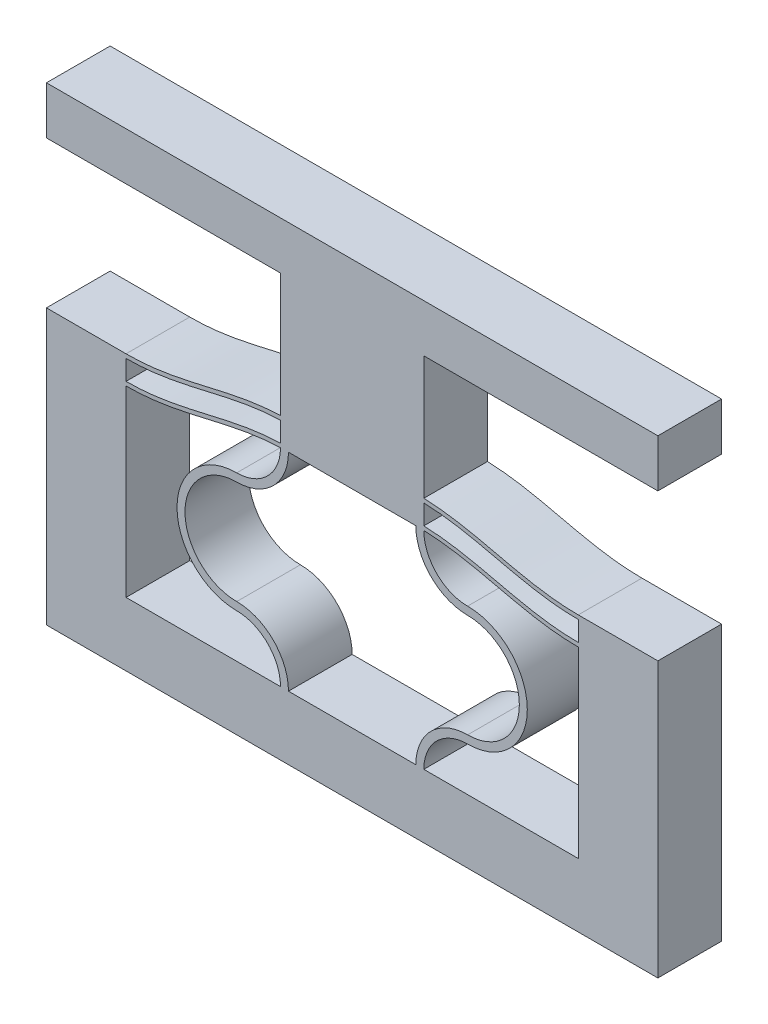
from build123d import *

# Parameters (mm, degrees)
BOSS_EXTRUDE1_DEPTH = 4
SKETCH4_W           = 1.000028655
SKETCH4_H           = 4
BOSS_EXTRUDE2_DEPTH = 1.5
SKETCH7_W           = 4
SKETCH7_H           = 4.491123012
SKETCH7_H_2         = 4
BOSS_EXTRUDE3_DEPTH = 4
MOVE_FACE1_BY       = 5
SKETCH8_W           = 38.400000218
SKETCH8_H           = 3
BOSS_EXTRUDE4_DEPTH = 4


with BuildPart() as part:
    # Sketch1 → Boss-Extrude1 (new body)
    with BuildSketch(Plane.XY):
        with BuildLine():
            add(Edge.make_bspline(
                [(10.700014224, 14.741123012), (10.769414318, 14.738663695), (11.03310814, 14.727603281), (11.490614063, 14.697170592), (12.262749669, 14.614202549), (13.344934017, 14.437909286), (14.416347819, 14.207015891), (15.483183095, 13.956131655), (16.319838847, 13.766249034), (16.857815383, 13.652304096), (17.362886901, 13.553302991), (17.776414428, 13.479790745), (18.203500731, 13.412396588), (18.656257538, 13.353987061), (18.987768381, 13.3179099), (19.289919617, 13.293036934), (19.513652899, 13.276508776), (19.742348402, 13.265861771), (19.917436469, 13.255829602), (20.20131205, 13.251344917), (20.318835942, 13.249999512), (20.4, 13.249999512)],
                knots=[0.520196639, 0.520196639, 0.520196639, 0.520196639, 0.520196639, 0.53141408, 0.562828159, 0.594242235, 0.645597029, 0.708425214, 0.739839305, 0.771253396, 0.784217346, 0.797181296, 0.823109196, 0.838816246, 0.854523296, 0.870230336, 0.878083855, 0.885937375, 0.893790894, 0.901644413, 0.917351451, 0.917351451, 0.917351451, 0.917351451, 0.917351451], degree=4))
            Line((10.700014224, 14.741123012), (10.700014224, 15.991123012))
            Line((10.700014224, 15.991123012), (9.699985569, 15.991123012))
            Line((9.699985569, 15.991123012), (9.699985569, 14.741123012))
            add(Edge.make_bspline(
                [(0, 13.249999512), (0.081164058, 13.249999512), (0.199729304, 13.251344907), (0.473779629, 13.255829663), (0.709191365, 13.267868104), (1.033438356, 13.285149543), (1.35158977, 13.312755641), (1.750162777, 13.353987577), (2.192328474, 13.412395709), (2.7057608, 13.49221948), (3.305792882, 13.602949191), (4.002230953, 13.748490017), (4.916593693, 13.956132269), (5.983810028, 14.207015465), (7.054976456, 14.437909533), (8.137289789, 14.614202431), (8.909375138, 14.697170645), (9.366886361, 14.727603295), (9.630584373, 14.738663696), (9.699985569, 14.741123012)],
                knots=[0.082648549, 0.082648549, 0.082648549, 0.082648549, 0.082648549, 0.098355587, 0.106209106, 0.114062625, 0.129769664, 0.145476704, 0.161183754, 0.176890804, 0.202818704, 0.228746604, 0.260160695, 0.291574786, 0.354402971, 0.405757765, 0.437171841, 0.46858592, 0.479803371, 0.479803371, 0.479803371, 0.479803371, 0.479803371], degree=4))
            Line((0, 13.249999512), (-5.000000005, 13.249999512))
            Line((-5.000000005, 13.249999512), (-5.000000005, -4))
            Line((-5.000000005, -4), (25.400000005, -4))
            Line((25.400000005, -4), (25.400000005, 13.249999512))
            Line((25.400000005, 13.249999512), (20.4, 13.249999512))
        make_face()
        with BuildLine():
            Line((9.699985569, 14.491123012), (9.699985569, 13.241123012))
            add(Edge.make_bspline(
                [(0, 11.749999512), (0.081164058, 11.749999512), (0.199729304, 11.751344907), (0.473779629, 11.755829663), (0.709191365, 11.767868104), (1.033438356, 11.785149543), (1.35158977, 11.812755641), (1.750162777, 11.853987577), (2.192328474, 11.912395709), (2.7057608, 11.99221948), (3.305792882, 12.102949191), (4.002230953, 12.248490017), (4.916593693, 12.456132269), (5.983810028, 12.707015465), (7.054976456, 12.937909533), (8.137289789, 13.114202431), (8.909375138, 13.197170645), (9.366886361, 13.227603295), (9.630584373, 13.238663696), (9.699985569, 13.241123012)],
                knots=[0.082648549, 0.082648549, 0.082648549, 0.082648549, 0.082648549, 0.098355587, 0.106209106, 0.114062625, 0.129769664, 0.145476704, 0.161183754, 0.176890804, 0.202818704, 0.228746604, 0.260160695, 0.291574786, 0.354402971, 0.405757765, 0.437171841, 0.46858592, 0.479803371, 0.479803371, 0.479803371, 0.479803371, 0.479803371], degree=4))
            Line((0, 11.749999512), (0, 12.999999512))
            add(Edge.make_bspline(
                [(0, 12.999999512), (0.081164058, 12.999999512), (0.199729304, 13.001344907), (0.473779629, 13.005829663), (0.709191365, 13.017868104), (1.033438356, 13.035149543), (1.35158977, 13.062755641), (1.750162777, 13.103987577), (2.192328474, 13.162395709), (2.7057608, 13.24221948), (3.305792882, 13.352949191), (4.002230953, 13.498490017), (4.916593693, 13.706132269), (5.983810028, 13.957015465), (7.054976456, 14.187909533), (8.137289789, 14.364202431), (8.909375138, 14.447170645), (9.366886361, 14.477603295), (9.630584373, 14.488663696), (9.699985569, 14.491123012)],
                knots=[0.082648549, 0.082648549, 0.082648549, 0.082648549, 0.082648549, 0.098355587, 0.106209106, 0.114062625, 0.129769664, 0.145476704, 0.161183754, 0.176890804, 0.202818704, 0.228746604, 0.260160695, 0.291574786, 0.354402971, 0.405757765, 0.437171841, 0.46858592, 0.479803371, 0.479803371, 0.479803371, 0.479803371, 0.479803371], degree=4))
        make_face(mode=Mode.SUBTRACT)
        with BuildLine():
            Line((10.700014224, 13.241123012), (10.700014224, 14.491123012))
            add(Edge.make_bspline(
                [(10.700014224, 14.491123012), (10.769414318, 14.488663695), (11.03310814, 14.477603281), (11.490614063, 14.447170592), (12.262749669, 14.364202549), (13.344934017, 14.187909286), (14.416347819, 13.957015891), (15.483183095, 13.706131655), (16.319838847, 13.516249034), (16.857815383, 13.402304096), (17.362886901, 13.303302991), (17.776414428, 13.229790745), (18.203500731, 13.162396588), (18.656257538, 13.103987061), (18.987768381, 13.0679099), (19.289919617, 13.043036934), (19.513652899, 13.026508776), (19.742348402, 13.015861771), (19.917436469, 13.005829602), (20.20131205, 13.001344917), (20.318835942, 12.999999512), (20.4, 12.999999512)],
                knots=[0.520196639, 0.520196639, 0.520196639, 0.520196639, 0.520196639, 0.53141408, 0.562828159, 0.594242235, 0.645597029, 0.708425214, 0.739839305, 0.771253396, 0.784217346, 0.797181296, 0.823109196, 0.838816246, 0.854523296, 0.870230336, 0.878083855, 0.885937375, 0.893790894, 0.901644413, 0.917351451, 0.917351451, 0.917351451, 0.917351451, 0.917351451], degree=4))
            Line((20.4, 12.999999512), (20.4, 11.749999512))
            add(Edge.make_bspline(
                [(10.700014224, 13.241123012), (10.769414318, 13.238663695), (11.03310814, 13.227603281), (11.490614063, 13.197170592), (12.262749669, 13.114202549), (13.344934017, 12.937909286), (14.416347819, 12.707015891), (15.483183095, 12.456131655), (16.319838847, 12.266249034), (16.857815383, 12.152304096), (17.362886901, 12.053302991), (17.776414428, 11.979790745), (18.203500731, 11.912396588), (18.656257538, 11.853987061), (18.987768381, 11.8179099), (19.289919617, 11.793036934), (19.513652899, 11.776508776), (19.742348402, 11.765861771), (19.917436469, 11.755829602), (20.20131205, 11.751344917), (20.318835942, 11.749999512), (20.4, 11.749999512)],
                knots=[0.520196639, 0.520196639, 0.520196639, 0.520196639, 0.520196639, 0.53141408, 0.562828159, 0.594242235, 0.645597029, 0.708425214, 0.739839305, 0.771253396, 0.784217346, 0.797181296, 0.823109196, 0.838816246, 0.854523296, 0.870230336, 0.878083855, 0.885937375, 0.893790894, 0.901644413, 0.917351451, 0.917351451, 0.917351451, 0.917351451, 0.917351451], degree=4))
        make_face(mode=Mode.SUBTRACT)
        with BuildLine():
            Line((0, 0), (0, 11.499999512))
            add(Edge.make_bspline(
                [(0, 11.499999512), (0.081164058, 11.499999512), (0.199729304, 11.501344907), (0.473779629, 11.505829663), (0.709191365, 11.517868104), (1.033438356, 11.535149543), (1.35158977, 11.562755641), (1.750162777, 11.603987577), (2.192328474, 11.662395709), (2.7057608, 11.74221948), (3.305792882, 11.852949191), (4.002230953, 11.998490017), (4.916593693, 12.206132269), (5.983810028, 12.457015465), (7.054976456, 12.687909533), (8.137289789, 12.864202431), (8.909375138, 12.947170645), (9.366886361, 12.977603295), (9.630584373, 12.988663696), (9.699985569, 12.991123012)],
                knots=[0.082648549, 0.082648549, 0.082648549, 0.082648549, 0.082648549, 0.098355587, 0.106209106, 0.114062625, 0.129769664, 0.145476704, 0.161183754, 0.176890804, 0.202818704, 0.228746604, 0.260160695, 0.291574786, 0.354402971, 0.405757765, 0.437171841, 0.46858592, 0.479803371, 0.479803371, 0.479803371, 0.479803371, 0.479803371], degree=4))
            ThreePointArc((9.699985569, 12.991123012), (8.891402518, 11.052320391), (6.949999896, 10.25))
            ThreePointArc((6.949999896, 10.25), (3.199999896, 6.5), (6.949999896, 2.75))
            ThreePointArc((6.949999896, 2.75), (8.894543545, 1.944543648), (9.699999896, 0))
            Line((9.699999896, 0), (0, 0))
        make_face(mode=Mode.SUBTRACT)
        with BuildLine():
            ThreePointArc((6.949999896, 9.75), (9.248096935, 10.701902961), (10.199999896, 13))
            ThreePointArc((10.199999896, 13), (11.151902857, 10.701902961), (13.449999896, 9.75))
            ThreePointArc((13.449999896, 9.75), (16.699999896, 6.5), (13.449999896, 3.25))
            ThreePointArc((13.449999896, 3.25), (11.151902857, 2.298097039), (10.199999896, 0))
            ThreePointArc((10.199999896, 0), (9.248096935, 2.298097039), (6.949999896, 3.25))
            ThreePointArc((6.949999896, 3.25), (3.699999896, 6.5), (6.949999896, 9.75))
        make_face(mode=Mode.SUBTRACT)
        with BuildLine():
            ThreePointArc((13.449999896, 10.25), (11.508597274, 11.052320391), (10.700014224, 12.991123012))
            add(Edge.make_bspline(
                [(10.700014224, 12.991123012), (10.769414318, 12.988663695), (11.03310814, 12.977603281), (11.490614063, 12.947170592), (12.262749669, 12.864202549), (13.344934017, 12.687909286), (14.416347819, 12.457015891), (15.483183095, 12.206131655), (16.319838847, 12.016249034), (16.857815383, 11.902304096), (17.362886901, 11.803302991), (17.776414428, 11.729790745), (18.203500731, 11.662396588), (18.656257538, 11.603987061), (18.987768381, 11.5679099), (19.289919617, 11.543036934), (19.513652899, 11.526508776), (19.742348402, 11.515861771), (19.917436469, 11.505829602), (20.20131205, 11.501344917), (20.318835942, 11.499999512), (20.4, 11.499999512)],
                knots=[0.520196639, 0.520196639, 0.520196639, 0.520196639, 0.520196639, 0.53141408, 0.562828159, 0.594242235, 0.645597029, 0.708425214, 0.739839305, 0.771253396, 0.784217346, 0.797181296, 0.823109196, 0.838816246, 0.854523296, 0.870230336, 0.878083855, 0.885937375, 0.893790894, 0.901644413, 0.917351451, 0.917351451, 0.917351451, 0.917351451, 0.917351451], degree=4))
            Line((20.4, 11.499999512), (20.4, 0))
            Line((20.4, 0), (10.699999896, 0))
            ThreePointArc((10.699999896, 0), (11.505456248, 1.944543648), (13.449999896, 2.75))
            ThreePointArc((13.449999896, 2.75), (17.199999896, 6.5), (13.449999896, 10.25))
        make_face(mode=Mode.SUBTRACT)
    extrude(amount=BOSS_EXTRUDE1_DEPTH)

    # Sketch4 → Boss-Extrude2 (add)
    with BuildSketch(Plane(origin=(0, 15.991123012, 0), x_dir=(1, 0, 0), z_dir=(0, 1, 0))):
        with Locations((10.199999896, -2)):
            Rectangle(SKETCH4_W, SKETCH4_H)
    extrude(amount=BOSS_EXTRUDE2_DEPTH)

    # Split2
    split(bisect_by=Plane(origin=(10.199999896, 0, 0), x_dir=(0, -1, 0), z_dir=(-1, 0, 0)), keep=Keep.BOTTOM)

    # Sketch7 → Boss-Extrude3 (add)
    with BuildSketch(Plane.ZY.offset(-10.199999896)):
        with Locations((2, 15.245561506)):
            Rectangle(SKETCH7_W, SKETCH7_H)
        with Locations((2, -2)):
            Rectangle(SKETCH7_W, SKETCH7_H_2)
    extrude(amount=BOSS_EXTRUDE3_DEPTH)

    # Mirror2: part across plane


with BuildPart() as part_1:
    add(part.part)
    add(part.part.mirror(Plane.ZY.offset(-6.199999896)))

    # Move Face1: a face moved outward by 5.0
    extrude(part_1.faces().sort_by_distance((6.199999896, 17.491123012, 2))[0], amount=MOVE_FACE1_BY, dir=(0, 1, 0))

    # Sketch8 → Boss-Extrude4 (add)
    with BuildSketch(Plane.XY.offset(4)):
        with Locations((6.199999896, 23.991123012)):
            Rectangle(SKETCH8_W, SKETCH8_H)
    extrude(amount=-BOSS_EXTRUDE4_DEPTH)


solid = part_1.part
